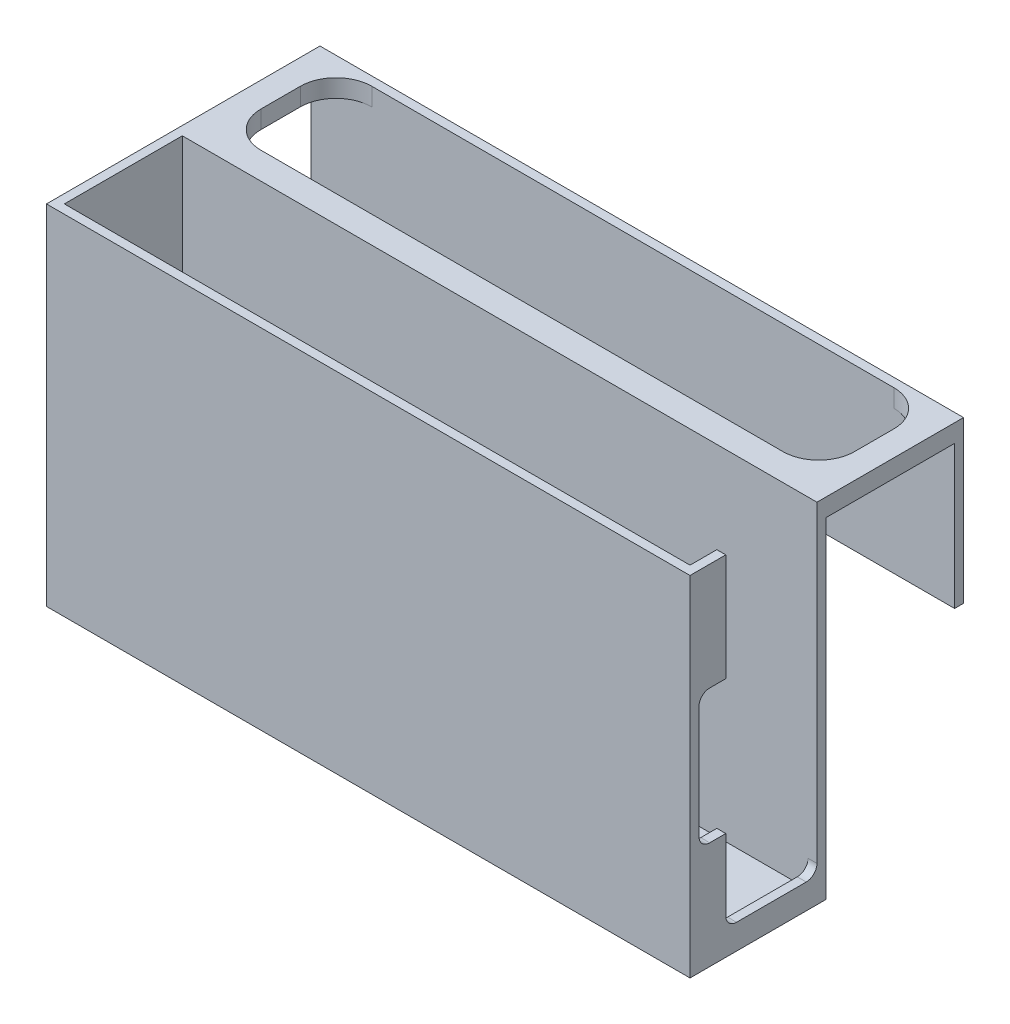
from build123d import *

# Parameters (mm, degrees)
SKETCH1_W           = 180
SKETCH1_H           = 97.5
BOSS_EXTRUDE1_DEPTH = 2.5
SKETCH2_W           = 180
SKETCH2_H           = 97.5
SKETCH2_W_2         = 175
SKETCH2_H_2         = 92.5
BOSS_EXTRUDE2_DEPTH = 33
SKETCH3_W           = 180
SKETCH3_H           = 97.5
BOSS_EXTRUDE3_DEPTH = 2.5
SKETCH4_W           = 180
SKETCH4_H           = 5
BOSS_EXTRUDE4_DEPTH = 38.5
SKETCH5_W           = 180
SKETCH5_H           = 2.5
BOSS_EXTRUDE5_DEPTH = 40
SKETCH7_W           = 175
SKETCH7_H           = 33
CUT_EXTRUDE2_DEPTH  = 2.5
CUT_EXTRUDE3_DEPTH  = 2.5
SKETCH12_W          = 166
SKETCH12_H          = 31
CUT_EXTRUDE5_DEPTH  = 5
FILLET1_R           = 10
FILLET2_R           = 10
FILLET3_R           = 10
FILLET4_R           = 10


with BuildPart() as part:
    # Sketch1 → Boss-Extrude1 (new body)
    with BuildSketch(Plane.XY):
        Rectangle(SKETCH1_W, SKETCH1_H)
    extrude(amount=BOSS_EXTRUDE1_DEPTH)

    # Sketch2 → Boss-Extrude2 (add)
    with BuildSketch(Plane(origin=(0, 0, 0), x_dir=(-1, 0, 0), z_dir=(0, 0, -1))):
        Rectangle(SKETCH2_W, SKETCH2_H)
        Rectangle(SKETCH2_W_2, SKETCH2_H_2, mode=Mode.SUBTRACT)
    extrude(amount=BOSS_EXTRUDE2_DEPTH)

    # Sketch3 → Boss-Extrude3 (add)
    with BuildSketch(Plane(origin=(0, 0, -33), x_dir=(-1, 0, 0), z_dir=(0, 0, -1))):
        Rectangle(SKETCH3_W, SKETCH3_H)
    extrude(amount=BOSS_EXTRUDE3_DEPTH)

    # Sketch4 → Boss-Extrude4 (add)
    with BuildSketch(Plane(origin=(0, 0, -35.5), x_dir=(-1, 0, 0), z_dir=(0, 0, -1))):
        with Locations((0, 46.25)):
            Rectangle(SKETCH4_W, SKETCH4_H)
    extrude(amount=BOSS_EXTRUDE4_DEPTH)

    # Sketch5 → Boss-Extrude5 (add)
    with BuildSketch(Plane.XZ.offset(-43.75)):
        with Locations((0, -72.75)):
            Rectangle(SKETCH5_W, SKETCH5_H)
    extrude(amount=BOSS_EXTRUDE5_DEPTH)

    # Sketch7 → Cut-Extrude2 (cut)
    with BuildSketch(Plane(origin=(0, 48.75, 0), x_dir=(1, 0, 0), z_dir=(0, 1, 0))):
        with Locations((0, 16.5)):
            Rectangle(SKETCH7_W, SKETCH7_H)
    extrude(amount=-CUT_EXTRUDE2_DEPTH, mode=Mode.SUBTRACT)

    # Sketch9 → Cut-Extrude3 (cut)
    with BuildSketch(Plane(origin=(90, 0, 0), x_dir=(0, 0, -1), z_dir=(1, 0, 0))):
        with BuildLine():
            Line((33, 48.75), (7.5, 48.75))
            Line((7.5, 48.75), (7.5, 18.75))
            Line((7.5, 18.75), (3, 18.75))
            ThreePointArc((3, 18.75), (0.878679656, 17.871320344), (0, 15.75))
            Line((0, 15.75), (0, -15.75))
            ThreePointArc((0, -15.75), (0.878679656, -17.871320344), (3, -18.75))
            Line((3, -18.75), (7.5, -18.75))
            Line((7.5, -18.75), (7.5, -38.75))
            ThreePointArc((7.5, -38.75), (8.378679656, -40.871320344), (10.5, -41.75))
            Line((10.5, -41.75), (30, -41.75))
            ThreePointArc((30, -41.75), (32.121320344, -40.871320344), (33, -38.75))
            Line((33, -38.75), (33, 48.75))
        make_face()
    extrude(amount=-CUT_EXTRUDE3_DEPTH, mode=Mode.SUBTRACT)

    # Sketch12 → Cut-Extrude5 (cut)
    with BuildSketch(Plane(origin=(0, 48.75, 0), x_dir=(1, 0, 0), z_dir=(0, 1, 0))):
        with Locations((0, 56)):
            Rectangle(SKETCH12_W, SKETCH12_H)
    extrude(amount=-CUT_EXTRUDE5_DEPTH, mode=Mode.SUBTRACT)

    # Fillet1
    fillet1_edges = [part.edges().sort_by_distance(p)[0] for p in [
        (83, 46.25, -40.5),
    ]]
    fillet(fillet1_edges, radius=FILLET1_R)

    # Fillet2
    fillet2_edges = [part.edges().sort_by_distance(p)[0] for p in [
        (83, 46.25, -71.5),
    ]]
    fillet(fillet2_edges, radius=FILLET2_R)

    # Fillet3
    fillet3_edges = [part.edges().sort_by_distance(p)[0] for p in [
        (-83, 46.25, -40.5),
    ]]
    fillet(fillet3_edges, radius=FILLET3_R)

    # Fillet4
    fillet4_edges = [part.edges().sort_by_distance(p)[0] for p in [
        (-83, 46.25, -71.5),
    ]]
    fillet(fillet4_edges, radius=FILLET4_R)


solid = part.part
